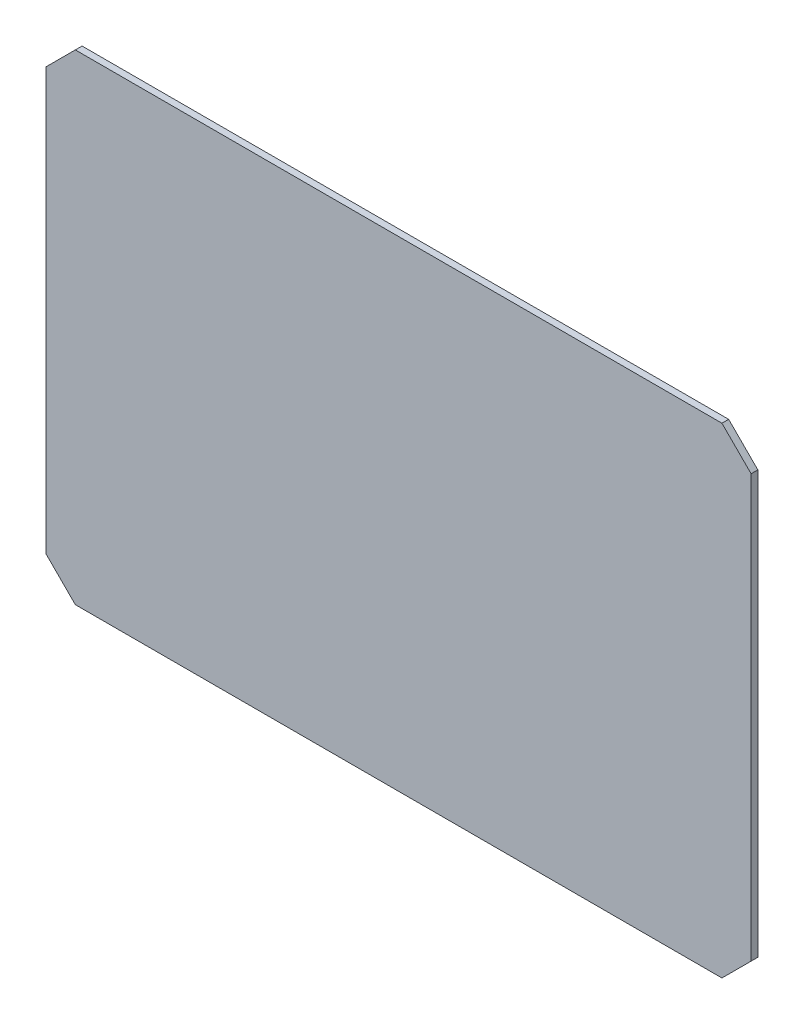
from build123d import *

# Parameters (mm, degrees)
EXTRUDE1_DEPTH = 3


with BuildPart() as part:
    # Sketch1 → Extrude1 (new body)
    with BuildSketch(Plane.XY):
        Polygon((144, -107), (-144, -107), (-157, -94), (-157, 94), (-144, 107), (144, 107), (157, 94), (157, -94), align=None)
    extrude(amount=EXTRUDE1_DEPTH)


solid = part.part
